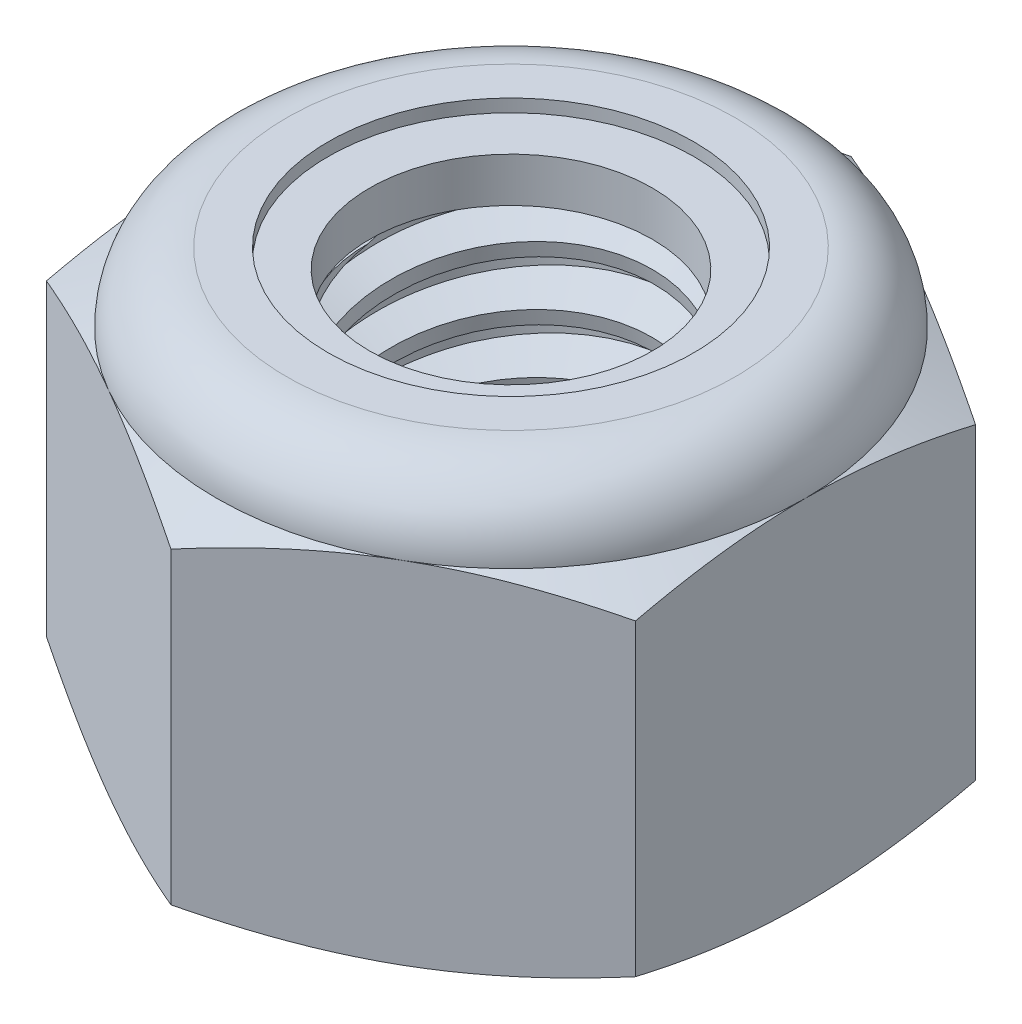
from build123d import *

# Parameters (mm, degrees)
EXTRUDE1_DEPTH      = 5
SKETCH2_W           = 2
SKETCH2_H           = 5
LPATTERN1_COUNT     = 7
LPATTERN1_PITCH     = 0.7
LPATTERN1_COL_COUNT = 2
LPATTERN1_COL_PITCH = 0.7


with BuildPart() as part:
    # Sketch1 → Extrude1 (new body)
    with BuildSketch(Plane(origin=(0, 0, 0), x_dir=(1, 0, 0), z_dir=(0, 1, 0))):
        Polygon((0, 4.041451884), (-3.5, 2.020725942), (-3.5, -2.020725942), (0, -4.041451884), (3.5, -2.020725942), (3.5, 2.020725942), align=None)
    extrude(amount=EXTRUDE1_DEPTH)

    # Sketch4 → Cut-Revolve2 (revolve, cut)
    with BuildSketch(Plane(origin=(0, 0, 0), x_dir=(0, 0, -1), z_dir=(1, 0, 0)), mode=Mode.PRIVATE) as cut_revolve2_sk:
        Polygon((0, 5), (2, 5), (1.679577111, 4.850584353), (1.679577111, 0.149415647), (2, 0), (0, 0), align=None)
    revolve(cut_revolve2_sk.sketch.rotate(Axis((0, 5, 0), (0, 1, 0)), 54.612382926), axis=Axis((0, 5, 0), (0, 1, 0)), mode=Mode.SUBTRACT)  # turned: the seam where the file's is


with BuildPart() as body_2:
    # Sketch2 → Revolve1 (revolve)
    with BuildSketch(Plane(origin=(0, 0, 0), x_dir=(0, 0, -1), z_dir=(1, 0, 0))):
        with Locations((1, 2.5)):
            Rectangle(SKETCH2_W, SKETCH2_H)
    revolve(axis=Axis((0, -2, 0), (0, 1, 0)))

    # Sketch3 → Cut-Revolve1 (revolve, cut)
    with BuildSketch(Plane(origin=(0, 0, 0), x_dir=(0, 0, -1), z_dir=(1, 0, 0)), mode=Mode.PRIVATE) as cut_revolve1_sk:
        Polygon((2.015083279, 4.913809834), (2.120666232, 4.310478673), (1.709743669, 4.460641574), (1.679577111, 4.633021905), align=None)
    cut_revolve1 = revolve(cut_revolve1_sk.sketch.rotate(Axis((0, 5, 0.13120342), (0, -0.985030467, -0.172380332)), 180), axis=Axis((0, 5, 0.13120342), (0, -0.985030467, -0.172380332)), mode=Mode.SUBTRACT)  # turned: the seam where the file's is

    # LPattern1: Cut-Revolve1 ×7
    with Locations(*[(0, -i * LPATTERN1_PITCH, 0) for i in range(1, LPATTERN1_COUNT)]):
        add(cut_revolve1, mode=Mode.SUBTRACT)

    # LPattern1 col: Cut-Revolve1 ×2
    with Locations(*[(0, i * LPATTERN1_COL_PITCH, 0) for i in range(1, LPATTERN1_COL_COUNT)]):
        add(cut_revolve1, mode=Mode.SUBTRACT)


with BuildPart() as part_1:
    add(part.part)

    # Combine1: cut body 2
    add(body_2.part, mode=Mode.SUBTRACT)

    # Sketch5 → Cut-Revolve3 (revolve, cut)
    with BuildSketch(Plane(origin=(0, 0, 0), x_dir=(0, 0, -1), z_dir=(1, 0, 0)), mode=Mode.PRIVATE) as cut_revolve3_sk:
        with BuildLine():
            Line((0, 0), (3.5, 0))
            Line((3.5, 0), (4.041451884, 0.25248316))
            Line((4.041451884, 0.25248316), (4.041451884, 3.914183506))
            Line((4.041451884, 3.914183506), (3.5, 4.166666667))
            ThreePointArc((3.5, 4.166666667), (3.255922318, 4.755922318), (2.666666667, 5))
            Line((2.666666667, 5), (2.666666667, 6.27))
            Line((2.666666667, 6.27), (5.311451884, 6.27))
            Line((5.311451884, 6.27), (5.311451884, -1.27))
            Line((5.311451884, -1.27), (0, -1.27))
            Line((0, -1.27), (0, 0))
        make_face()
    revolve(cut_revolve3_sk.sketch.rotate(Axis((0, 0, 0), (0, 1, 0)), 54.612382926), axis=Axis((0, 0, 0), (0, 1, 0)), mode=Mode.SUBTRACT)  # turned: the seam where the file's is

    # Sketch6 → Cut-Revolve4 (revolve, cut)
    with BuildSketch(Plane(origin=(0, 0, 0), x_dir=(0, 0, -1), z_dir=(1, 0, 0)), mode=Mode.PRIVATE) as cut_revolve4_sk:
        with BuildLine():
            Line((0, 4.166666667), (3.3476, 4.166666667))
            ThreePointArc((3.3476, 4.166666667), (3.148159244, 4.648159244), (2.666666667, 4.8476))
            Line((2.666666667, 4.8476), (2.173121889, 4.8476))
            Line((2.173121889, 4.8476), (2.173121889, 6.27))
            Line((2.173121889, 6.27), (0, 6.27))
            Line((0, 6.27), (0, 4.166666667))
        make_face()
    revolve(cut_revolve4_sk.sketch.rotate(Axis((0, 6.27, 0), (0, 1, 0)), 54.612382926), axis=Axis((0, 6.27, 0), (0, 1, 0)), mode=Mode.SUBTRACT)  # turned: the seam where the file's is


with BuildPart() as body_2_2:
    # Sketch7 → Revolve2 (revolve)
    with BuildSketch(Plane(origin=(0, 0, 0), x_dir=(0, 0, -1), z_dir=(1, 0, 0))):
        with BuildLine():
            Line((1.679577111, 4.242866667), (3.266579964, 4.242866667))
            ThreePointArc((3.266579964, 4.242866667), (3.066430175, 4.620419399), (2.666666667, 4.7714))
            Line((2.666666667, 4.7714), (1.679577111, 4.7714))
            Line((1.679577111, 4.7714), (1.679577111, 4.242866667))
        make_face()
    revolve(axis=Axis((0, 4.242866667, 0), (0, 1, 0)))


solid = Compound([part_1.part, body_2_2.part])
